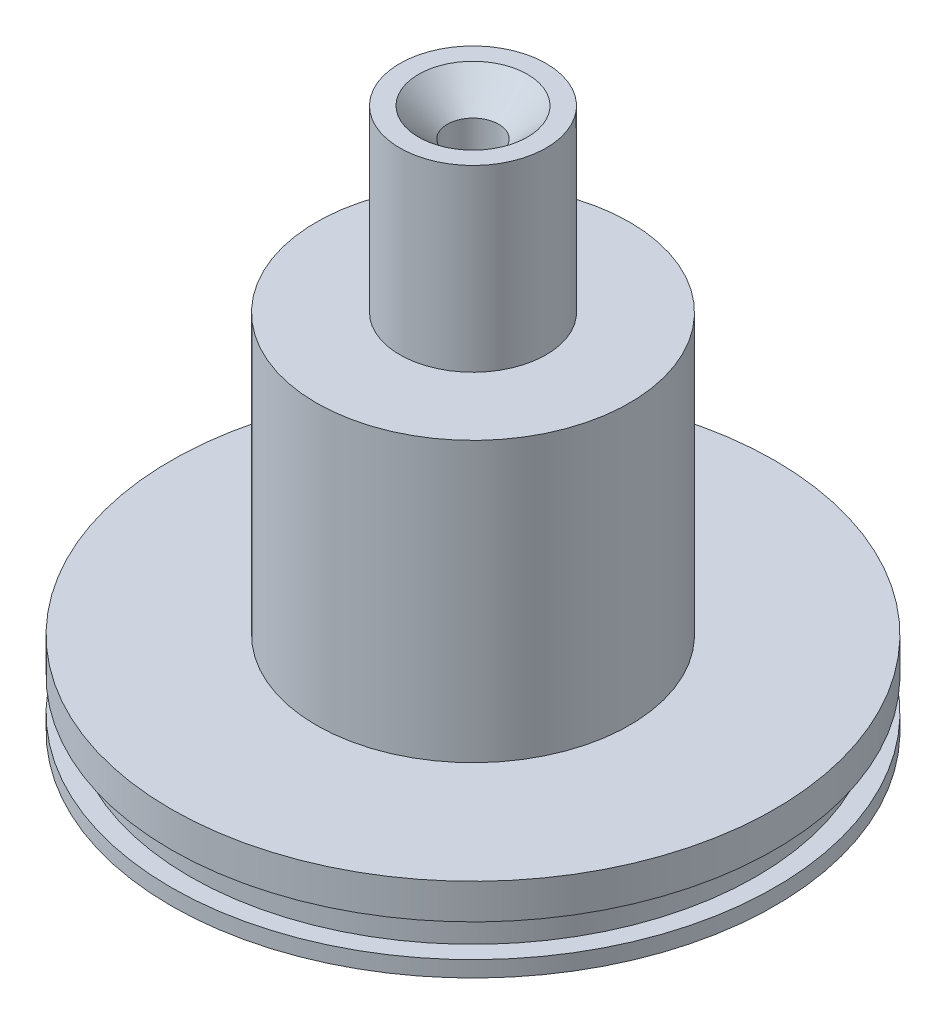
from build123d import *


with BuildPart() as part:
    # Sketch1 → Revolve1 (revolve)
    with BuildSketch(Plane.XY):
        Polygon((19.1516, 0), (19.1516, 50.8), (0, 50.8), (0, 55.0164), (3.8862, 55.0164), (3.8862, 77.8002), (8.255, 82.169), (11.0998, 82.169), (11.0998, 55.0164), (23.749, 55.0164), (23.749, 12.7), (45.7708, 12.7), (45.7708, 7.366), (42.926, 7.366), (42.926, 2.413), (45.7708, 2.413), (45.7708, 0), align=None)
    revolve(axis=Axis((0, 50.8, 0), (0, 1, 0)))


solid = part.part
